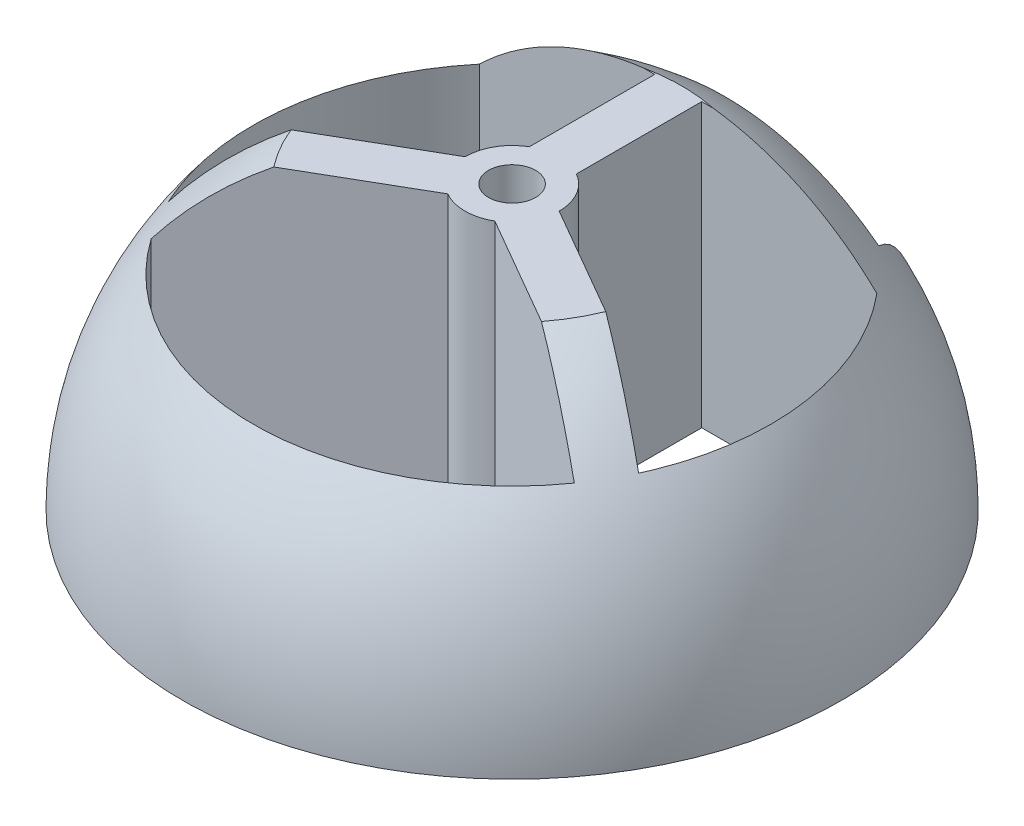
from build123d import *

# Parameters (mm, degrees)
SKETCH4_R                = 11
CUT_EXTRUDE4_DEPTH       = 25.248711
CUT_EXTRUDE5_DEPTH       = 22.610183
BOSS_EXTRUDE1_REACH      = 23.61
BOSS_EXTRUDE1_END_RADIUS = 14
SKETCH5_R                = 1
SKETCH7_W                = 20.713315
SKETCH7_H                = 3.375348
CUT_EXTRUDE6_DEPTH       = 25.228083
CUT_EXTRUDE6_DEPTH_BACK  = 25.228083


with BuildPart() as part:
    # Sketch1 → Revolve1 (revolve)
    with BuildSketch(Plane.XY):
        with BuildLine():
            Line((0, 14), (0, 0))
            Line((0, 0), (14, 0))
            ThreePointArc((14, 0), (9.899495, 9.899495), (0, 14))
        make_face()
    revolve(axis=Axis((0, -754.629412, 0), (0, 1, 0)))

    # Sketch4 → Cut-Extrude4 (cut, through all)
    with BuildSketch(Plane(origin=(0, 0, 0), x_dir=(1, 0, 0), z_dir=(0, 1, 0))):
        with Locations(Location((0, 0, 0), (0, 0, 90))):
            Circle(SKETCH4_R)
    extrude(amount=CUT_EXTRUDE4_DEPTH, mode=Mode.SUBTRACT)

    # Sketch6 → Cut-Extrude5 (cut, through all)
    with BuildSketch(Plane(origin=(0, 0, 0), x_dir=(1, 0, 0), z_dir=(0, 1, 0))):
        with BuildLine():
            Line((-6.517247, 9.056408), (6.517247, 9.056408))
            Line((6.517247, 9.056408), (4, 13.416408))
            ThreePointArc((4, 13.416408), (0, 14), (-4, 13.416408))
            Line((-4, 13.416408), (-6.517247, 9.056408))
        make_face()
    extrude(amount=CUT_EXTRUDE5_DEPTH, mode=Mode.SUBTRACT)

    # Boss-Extrude1: up to this sphere (the profile starts inside it)
    boss_extrude1_end = Location((0, 0, 0)) * Sphere(BOSS_EXTRUDE1_END_RADIUS, mode=Mode.PRIVATE)
    # Sketch5 → Boss-Extrude1 (add, up to the surface)
    with BuildSketch(Plane(origin=(0, 0, 0), x_dir=(1, 0, 0), z_dir=(0, 1, 0)), mode=Mode.PRIVATE) as boss_extrude1_sk1:
        with BuildLine():
            Line((-8.43843, 7.056408), (-1, 7.056408))
            Line((-1, 7.056408), (-1, 1.732051))
            ThreePointArc((-1, 1.732051), (-1.732051, 1), (-2, 0))
            Line((-2, 0), (-12.593387, -6.116095))
            Line((-12.593387, -6.116095), (-11.593387, -7.848145))
            Line((-11.593387, -7.848145), (-1, -1.732051))
            ThreePointArc((-1, -1.732051), (0, -2), (1, -1.732051))
            Line((1, -1.732051), (11.593387, -7.848145))
            Line((11.593387, -7.848145), (12.593387, -6.116095))
            Line((12.593387, -6.116095), (2, 0))
            ThreePointArc((2, 0), (1.732051, 1), (1, 1.732051))
            Line((1, 1.732051), (1, 7.056408))
            Line((1, 7.056408), (8.43843, 7.056408))
            Line((8.43843, 7.056408), (8.43843, 9.056408))
            Line((8.43843, 9.056408), (-8.43843, 9.056408))
            Line((-8.43843, 9.056408), (-8.43843, 7.056408))
        make_face()
        with Locations(Location((0, 0, 0), (0, 0, 90))):
            Circle(SKETCH5_R, mode=Mode.SUBTRACT)
    boss_extrude1_tool1 = extrude(boss_extrude1_sk1.sketch, amount=BOSS_EXTRUDE1_REACH, mode=Mode.PRIVATE) & boss_extrude1_end
    add(boss_extrude1_tool1.solids().sort_by_distance((0, 0, -1.246464))[0])

    # Sketch7 → Cut-Extrude6 (cut, two sides)
    with BuildSketch(Plane.XY) as cut_extrude6_sk:
        with Locations((0.377369, 13.687674)):
            Rectangle(SKETCH7_W, SKETCH7_H)
    extrude(amount=CUT_EXTRUDE6_DEPTH, mode=Mode.SUBTRACT)
    extrude(cut_extrude6_sk.sketch, amount=-CUT_EXTRUDE6_DEPTH_BACK, mode=Mode.SUBTRACT)


solid = part.part
